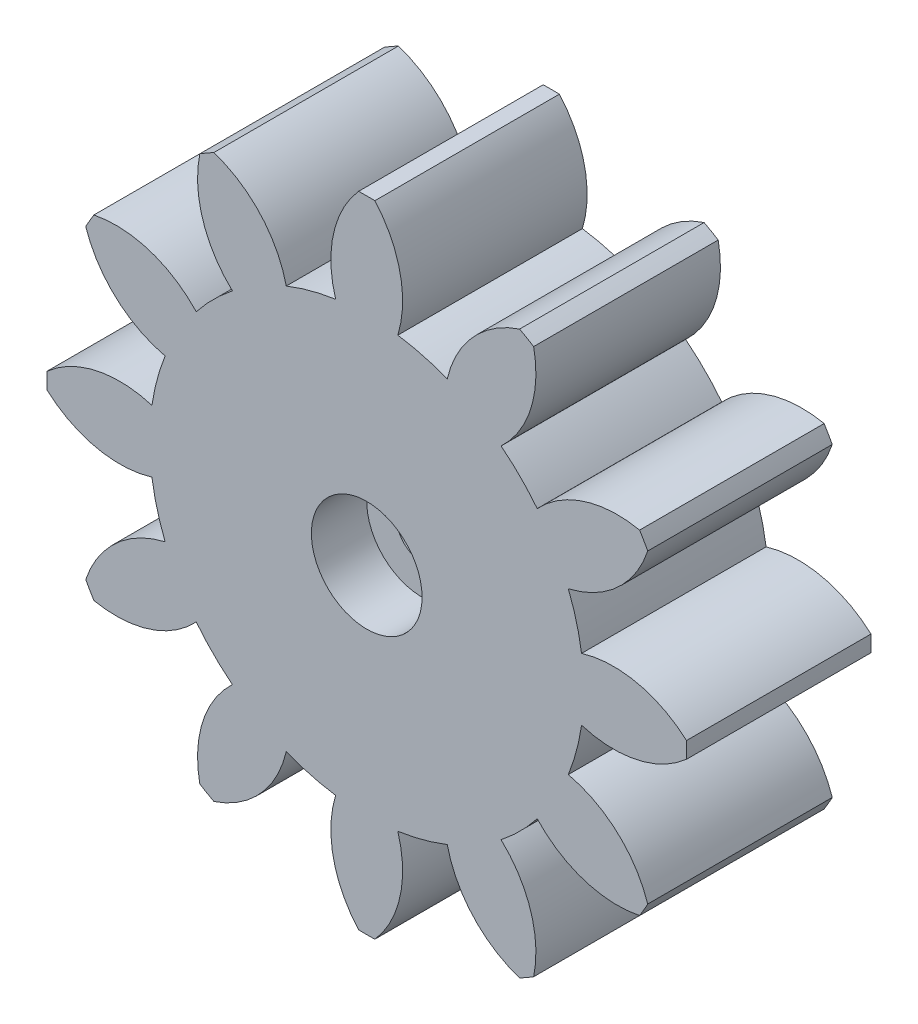
from build123d import *

# Parameters (mm, degrees)
BOSS_EXTRUDE1_DEPTH = 10
SKETCH3_R           = 3
CUT_EXTRUDE1_DEPTH  = 3
SKETCH4_R           = 3
CUT_EXTRUDE2_DEPTH  = 5
CUT_EXTRUDE3_REACH  = 7
SKETCH5_R           = 1.375
CUT_EXTRUDE4_DEPTH  = 0.4


with BuildPart() as part:
    # Sketch1 → Boss-Extrude1 (new body)
    with BuildSketch(Plane.XY):
        with BuildLine():
            ThreePointArc((10.92443124, -4.361437941), (11.362069294, -3.044457292), (11.641553947, -1.685099566))
            ThreePointArc((11.641553947, -1.685099566), (14.648632583, -1.806960077), (17.329910897, -0.440168758))
            ThreePointArc((17.329910897, -0.440168758), (17.3355, 0), (17.329910897, 0.440168758))
            ThreePointArc((17.329910897, 0.440168758), (14.648632583, 1.806960077), (11.641553947, 1.685099566))
            ThreePointArc((11.641553947, 1.685099566), (11.362069294, 3.044457292), (10.92443124, 4.361437941))
            ThreePointArc((10.92443124, 4.361437941), (13.589567986, 5.759442961), (15.228227462, 8.283758122))
            ThreePointArc((15.228227462, 8.283758122), (15.012983387, 8.66775), (14.788058703, 9.046152775))
            ThreePointArc((14.788058703, 9.046152775), (11.782607909, 8.889189622), (9.239331674, 7.280116005))
            ThreePointArc((9.239331674, 7.280116005), (8.317612002, 8.317612002), (7.280116005, 9.239331674))
            ThreePointArc((7.280116005, 9.239331674), (8.889189622, 11.782607909), (9.046152775, 14.788058703))
            ThreePointArc((9.046152775, 14.788058703), (8.66775, 15.012983387), (8.283758122, 15.228227462))
            ThreePointArc((8.283758122, 15.228227462), (5.759442961, 13.589567986), (4.361437941, 10.92443124))
            ThreePointArc((4.361437941, 10.92443124), (3.044457292, 11.362069294), (1.685099566, 11.641553947))
            ThreePointArc((1.685099566, 11.641553947), (1.806960077, 14.648632583), (0.440168758, 17.329910897))
            ThreePointArc((0.440168758, 17.329910897), (0, 17.3355), (-0.440168758, 17.329910897))
            ThreePointArc((-0.440168758, 17.329910897), (-1.806960077, 14.648632583), (-1.685099566, 11.641553947))
            ThreePointArc((-1.685099566, 11.641553947), (-3.044457292, 11.362069294), (-4.361437941, 10.92443124))
            ThreePointArc((-4.361437941, 10.92443124), (-5.759442961, 13.589567986), (-8.283758122, 15.228227462))
            ThreePointArc((-8.283758122, 15.228227462), (-8.66775, 15.012983387), (-9.046152775, 14.788058703))
            ThreePointArc((-9.046152775, 14.788058703), (-8.889189622, 11.782607909), (-7.280116005, 9.239331674))
            ThreePointArc((-7.280116005, 9.239331674), (-8.317612002, 8.317612002), (-9.239331674, 7.280116005))
            ThreePointArc((-9.239331674, 7.280116005), (-11.782607909, 8.889189622), (-14.788058703, 9.046152775))
            ThreePointArc((-14.788058703, 9.046152775), (-15.012983387, 8.66775), (-15.228227462, 8.283758122))
            ThreePointArc((-15.228227462, 8.283758122), (-13.589567986, 5.759442961), (-10.92443124, 4.361437941))
            ThreePointArc((-10.92443124, 4.361437941), (-11.362069294, 3.044457292), (-11.641553947, 1.685099566))
            ThreePointArc((-11.641553947, 1.685099566), (-14.648632583, 1.806960077), (-17.329910897, 0.440168758))
            ThreePointArc((-17.329910897, 0.440168758), (-17.3355, 0), (-17.329910897, -0.440168758))
            ThreePointArc((-17.329910897, -0.440168758), (-14.648632583, -1.806960077), (-11.641553947, -1.685099566))
            ThreePointArc((-11.641553947, -1.685099566), (-11.362069294, -3.044457292), (-10.92443124, -4.361437941))
            ThreePointArc((-10.92443124, -4.361437941), (-13.589567986, -5.759442961), (-15.228227462, -8.283758122))
            ThreePointArc((-15.228227462, -8.283758122), (-15.012983387, -8.66775), (-14.788058703, -9.046152775))
            ThreePointArc((-14.788058703, -9.046152775), (-11.782607909, -8.889189622), (-9.239331674, -7.280116005))
            ThreePointArc((-9.239331674, -7.280116005), (-8.317612002, -8.317612002), (-7.280116005, -9.239331674))
            ThreePointArc((-7.280116005, -9.239331674), (-8.889189622, -11.782607909), (-9.046152775, -14.788058703))
            ThreePointArc((-9.046152775, -14.788058703), (-8.66775, -15.012983387), (-8.283758122, -15.228227462))
            ThreePointArc((-8.283758122, -15.228227462), (-5.759442961, -13.589567986), (-4.361437941, -10.92443124))
            ThreePointArc((-4.361437941, -10.92443124), (-3.044457292, -11.362069294), (-1.685099566, -11.641553947))
            ThreePointArc((-1.685099566, -11.641553947), (-1.806960077, -14.648632583), (-0.440168758, -17.329910897))
            ThreePointArc((-0.440168758, -17.329910897), (0, -17.3355), (0.440168758, -17.329910897))
            ThreePointArc((0.440168758, -17.329910897), (1.806960077, -14.648632583), (1.685099566, -11.641553947))
            ThreePointArc((1.685099566, -11.641553947), (3.044457292, -11.362069294), (4.361437941, -10.92443124))
            ThreePointArc((4.361437941, -10.92443124), (5.759442961, -13.589567986), (8.283758122, -15.228227462))
            ThreePointArc((8.283758122, -15.228227462), (8.66775, -15.012983387), (9.046152775, -14.788058703))
            ThreePointArc((9.046152775, -14.788058703), (8.889189622, -11.782607909), (7.280116005, -9.239331674))
            ThreePointArc((7.280116005, -9.239331674), (8.317612002, -8.317612002), (9.239331674, -7.280116005))
            ThreePointArc((9.239331674, -7.280116005), (11.782607909, -8.889189622), (14.788058703, -9.046152775))
            ThreePointArc((14.788058703, -9.046152775), (15.012983387, -8.66775), (15.228227462, -8.283758122))
            ThreePointArc((15.228227462, -8.283758122), (13.589567986, -5.759442961), (10.92443124, -4.361437941))
        make_face()
    extrude(amount=BOSS_EXTRUDE1_DEPTH)

    # Sketch3 → Cut-Extrude1 (cut)
    with BuildSketch(Plane.XY.offset(10)):
        Circle(SKETCH3_R)
    extrude(amount=-CUT_EXTRUDE1_DEPTH, mode=Mode.SUBTRACT)

    # Sketch4 → Cut-Extrude2 (cut)
    with BuildSketch(Plane(origin=(0, 0, 0), x_dir=(-1, 0, 0), z_dir=(0, 0, -1))):
        Circle(SKETCH4_R)
    extrude(amount=-CUT_EXTRUDE2_DEPTH, mode=Mode.SUBTRACT)

    # Sketch5 → Cut-Extrude3 (cut, up to next)
    with BuildSketch(Plane(origin=(0, 0, 5), x_dir=(-1, 0, 0), z_dir=(0, 0, -1)), mode=Mode.PRIVATE) as cut_extrude3_sk1:
        Circle(SKETCH5_R)
    cut_extrude3_tool1 = extrude(cut_extrude3_sk1.sketch, amount=-CUT_EXTRUDE3_REACH, mode=Mode.PRIVATE) & part.part
    add(cut_extrude3_tool1.solids().sort_by_distance((0, 0, 5))[0], mode=Mode.SUBTRACT)

    # Sketch6 → Cut-Extrude4 (cut)
    with BuildSketch(Plane(origin=(0, 0, 0), x_dir=(-1, 0, 0), z_dir=(0, 0, -1))):
        Polygon((-2.618216479, 7.598722954), (-1.369925881, 7.598722954), (-1.397062633, 7.408765689), (-1.914356971, 7.408765689), (-2.18275641, 5.482056288), (-2.37398571, 5.482056288), (-2.105586271, 7.408765689), (-2.645353231, 7.408765689), align=None)
        with BuildLine():
            add(Edge.make_bspline(
                [(-0.466780849, 7.055987912), (-0.450230711, 7.05582637), (-0.417344464, 7.055505377), (-0.368540996, 7.050389965), (-0.320631892, 7.043455272), (-0.273890681, 7.033209653), (-0.228274333, 7.020039405), (-0.183797047, 7.003718771), (-0.139886963, 6.985373988), (-0.097861943, 6.963061744), (-0.056959643, 6.93914658), (-0.018469172, 6.912248414), (0.018217553, 6.883553528), (0.05209848, 6.852068656), (0.083565028, 6.818384713), (0.113001423, 6.782640371), (0.140098105, 6.744546559), (0.164595462, 6.704227452), (0.186767697, 6.662267959), (0.205810076, 6.618582201), (0.221812473, 6.573454595), (0.235635063, 6.527284032), (0.245748638, 6.479469202), (0.252716265, 6.430299353), (0.25780439, 6.379794636), (0.25811986, 6.345639936), (0.258279247, 6.328383745)],
                knots=[0, 0, 0, 0, 4.9626e-05, 9.861e-05, 0.000147062, 0.000194801, 0.000242036, 0.000289383, 0.000336874, 0.000384665, 0.000432005, 0.000478934, 0.000525421, 0.000571629, 0.000617526, 0.000663618, 0.000710444, 0.000757639, 0.000805055, 0.000852714, 0.00090046, 0.000948628, 0.000997195, 0.001046906, 0.001097579, 0.001149324, 0.001149324, 0.001149324, 0.001149324], degree=3))
            add(Edge.make_bspline(
                [(0.258279247, 6.328383745), (0.258039783, 6.308578593), (0.257564863, 6.269299702), (0.25111703, 6.210994824), (0.242013556, 6.153590639), (0.228820877, 6.097203636), (0.211893663, 6.041919503), (0.190810327, 5.98797899), (0.166897365, 5.934727262), (0.138391513, 5.883395436), (0.107072302, 5.833870752), (0.073382761, 5.786755537), (0.036549617, 5.742935538), (-0.002372315, 5.701702817), (-0.04403848, 5.66345401), (-0.088426282, 5.628104243), (-0.135229578, 5.595522836), (-0.184676123, 5.566327033), (-0.235762168, 5.539867628), (-0.289219479, 5.517520108), (-0.344037548, 5.497877287), (-0.400776526, 5.482306102), (-0.458924002, 5.469780542), (-0.519048579, 5.461676665), (-0.580721407, 5.455726724), (-0.622519609, 5.455190096), (-0.643593749, 5.454919536)],
                knots=[0, 0, 0, 0, 5.9386e-05, 0.000117778, 0.000175775, 0.00023368, 0.000291352, 0.00034907, 0.000407322, 0.000466339, 0.000525038, 0.000583054, 0.000639949, 0.000696635, 0.000753052, 0.000809471, 0.000866752, 0.000923981, 0.00098163, 0.001039198, 0.001097669, 0.001156204, 0.001215581, 0.001275965, 0.001338116, 0.001401316, 0.001401316, 0.001401316, 0.001401316], degree=3))
            add(Edge.make_bspline(
                [(-0.643593749, 5.454919536), (-0.669493428, 5.455383045), (-0.720215087, 5.456290778), (-0.79439634, 5.466548474), (-0.865066012, 5.482132761), (-0.932596844, 5.503609688), (-0.996247222, 5.532258194), (-1.056572504, 5.566773789), (-1.113195168, 5.607790827), (-1.165981922, 5.654584393), (-1.213474215, 5.70648827), (-1.255599117, 5.761915733), (-1.290839566, 5.821150442), (-1.31984552, 5.88380972), (-1.342346636, 5.949908511), (-1.358542659, 6.019333173), (-1.367836177, 6.092239873), (-1.369220429, 6.141933883), (-1.369925881, 6.167259279)],
                knots=[0, 0, 0, 0, 7.7651e-05, 0.000152071, 0.000224184, 0.000294581, 0.000364239, 0.000433188, 0.000502737, 0.00057362, 0.000644441, 0.00071347, 0.000782116, 0.000850791, 0.000920249, 0.000991216, 0.00106432, 0.001140294, 0.001140294, 0.001140294, 0.001140294], degree=3))
            add(Edge.make_bspline(
                [(-1.369925881, 6.167259279), (-1.369686634, 6.187346849), (-1.369212104, 6.227189251), (-1.362759891, 6.286341002), (-1.353696191, 6.344455032), (-1.340515163, 6.40142391), (-1.323365754, 6.45698532), (-1.303239948, 6.51160935), (-1.278207847, 6.564567741), (-1.250581409, 6.616609619), (-1.219162465, 6.666555184), (-1.184856791, 6.713974777), (-1.147928001, 6.75876754), (-1.107808488, 6.800408128), (-1.065080124, 6.839424555), (-1.019448587, 6.875464179), (-0.9715212, 6.909223719), (-0.920623878, 6.939512396), (-0.868016329, 6.966960034), (-0.813961342, 6.990907617), (-0.758740152, 7.010651127), (-0.702629226, 7.02747186), (-0.645186655, 7.040029408), (-0.586743519, 7.049425439), (-0.527104511, 7.055120684), (-0.487004359, 7.055697173), (-0.466780849, 7.055987912)],
                knots=[0, 0, 0, 0, 6.0234e-05, 0.000119469, 0.000178303, 0.000236621, 0.000294699, 0.000352663, 0.000411092, 0.000470279, 0.000529337, 0.000587944, 0.000645762, 0.000703341, 0.000761269, 0.000819212, 0.000877673, 0.00093701, 0.000996749, 0.001055602, 0.001114215, 0.001172576, 0.001231214, 0.001290467, 0.001350084, 0.001410741, 0.001410741, 0.001410741, 0.001410741], degree=3))
        make_face()
        with BuildLine():
            add(Edge.make_bspline(
                [(-0.472293002, 6.866030647), (-0.503747094, 6.865022695), (-0.566133209, 6.863023522), (-0.658065178, 6.845395471), (-0.74697014, 6.81671419), (-0.8179001, 6.783908088), (-0.872314578, 6.752977498), (-0.910614571, 6.727193913), (-0.946742967, 6.69944908), (-0.979981554, 6.669196258), (-1.011627398, 6.637641618), (-1.040171419, 6.603265542), (-1.066329268, 6.566962809), (-1.097983096, 6.516104928), (-1.130880322, 6.448766532), (-1.159486048, 6.363291926), (-1.176996833, 6.273551961), (-1.178969506, 6.212282932), (-1.179968616, 6.181251667)],
                knots=[0, 0, 0, 0, 9.4292e-05, 0.000187019, 0.000279676, 0.000373968, 0.00042088, 0.000467332, 0.000512367, 0.000557404, 0.000602079, 0.000646324, 0.000691278, 0.000736223, 0.000825918, 0.000915352, 0.001005996, 0.001099018, 0.001099018, 0.001099018, 0.001099018], degree=3))
            add(Edge.make_bspline(
                [(-1.179968616, 6.181251667), (-1.1794568, 6.161867569), (-1.178451954, 6.123810792), (-1.171245103, 6.068109016), (-1.158915609, 6.015297828), (-1.141843388, 5.965306456), (-1.120166741, 5.91788484), (-1.093381959, 5.873158688), (-1.061329114, 5.831519246), (-1.024961279, 5.793010338), (-0.984651842, 5.758346576), (-0.941503542, 5.727691836), (-0.895161957, 5.701906395), (-0.845807108, 5.681429065), (-0.794011633, 5.664525813), (-0.73908174, 5.653428903), (-0.681546468, 5.645797717), (-0.642065378, 5.645187438), (-0.62196915, 5.644876801)],
                knots=[0, 0, 0, 0, 5.8145e-05, 0.000114157, 0.000168153, 0.000220581, 0.000272377, 0.000324297, 0.000376622, 0.000429712, 0.000482923, 0.000535862, 0.000588248, 0.000641641, 0.000695949, 0.000751417, 0.000809532, 0.000869779, 0.000869779, 0.000869779, 0.000869779], degree=3))
            add(Edge.make_bspline(
                [(-0.62196915, 5.644876801), (-0.590524141, 5.645933886), (-0.528763332, 5.648010096), (-0.438477158, 5.664456418), (-0.352929935, 5.691901598), (-0.272103007, 5.729454032), (-0.197778454, 5.777916968), (-0.130845563, 5.836279067), (-0.071984641, 5.904158073), (-0.022332757, 5.980832092), (0.017761416, 6.063614509), (0.047409032, 6.150361963), (0.064739616, 6.24049149), (0.067121094, 6.301457184), (0.068321982, 6.332199851)],
                knots=[0, 0, 0, 0, 9.4292e-05, 0.000185198, 0.000274236, 0.000363199, 0.000451756, 0.000539509, 0.000628779, 0.000720394, 0.000812747, 0.00090406, 0.000994703, 0.001086905, 0.001086905, 0.001086905, 0.001086905], degree=3))
            add(Edge.make_bspline(
                [(0.068321982, 6.332199851), (0.067596039, 6.357703768), (0.066178212, 6.407515064), (0.052490613, 6.479882494), (0.031000633, 6.547823061), (0.000738925, 6.610911353), (-0.037430539, 6.668381502), (-0.083276432, 6.719204496), (-0.136040802, 6.763624821), (-0.195880428, 6.799826465), (-0.259971579, 6.829850478), (-0.328268896, 6.850426904), (-0.399271241, 6.863689881), (-0.447781945, 6.865244927), (-0.472293002, 6.866030647)],
                knots=[0, 0, 0, 0, 7.644e-05, 0.000149293, 0.000220094, 0.000289696, 0.000358492, 0.000426347, 0.000494371, 0.000564622, 0.000635577, 0.000706124, 0.000778068, 0.000851544, 0.000851544, 0.000851544, 0.000851544], degree=3))
        make_face(mode=Mode.SUBTRACT)
        with BuildLine():
            Line((0.776421608, 7.02885116), (0.967650909, 7.02885116))
            Line((0.967650909, 7.02885116), (0.932457933, 6.781228296))
            add(Edge.make_bspline(
                [(0.932457933, 6.781228296), (0.95525764, 6.803138201), (1.000002938, 6.846137227), (1.072430641, 6.902257527), (1.147347384, 6.949518214), (1.224612839, 6.988624493), (1.304555777, 7.018705794), (1.386761654, 7.040508587), (1.471519696, 7.05361281), (1.528855179, 7.05518975), (1.557875268, 7.055987912)],
                knots=[0, 0, 0, 0, 9.4812e-05, 0.000186072, 0.0002743, 0.0003602, 0.000445409, 0.000530053, 0.000614965, 0.000701991, 0.000701991, 0.000701991, 0.000701991], degree=3))
            add(Edge.make_bspline(
                [(1.557875268, 7.055987912), (1.584192867, 7.055471337), (1.635869811, 7.054456997), (1.711516019, 7.044905152), (1.783549539, 7.029392819), (1.851757058, 7.00707545), (1.916555994, 6.979203097), (1.97753369, 6.944637972), (2.03469906, 6.903571981), (2.087708757, 6.856739674), (2.136102849, 6.805245178), (2.178144461, 6.749427894), (2.214259749, 6.690243954), (2.242868415, 6.626972477), (2.266096403, 6.56066932), (2.282154079, 6.490571495), (2.29146759, 6.416830902), (2.292836344, 6.366430373), (2.293535658, 6.340680086)],
                knots=[0, 0, 0, 0, 7.8922e-05, 0.00015497, 0.000228326, 0.000299661, 0.000369924, 0.000439609, 0.000509503, 0.000580703, 0.000651501, 0.000721124, 0.000789988, 0.000859049, 0.000929045, 0.001000425, 0.00107437, 0.001151615, 0.001151615, 0.001151615, 0.001151615], degree=3))
            add(Edge.make_bspline(
                [(2.293535658, 6.340680086), (2.292756814, 6.310809362), (2.291221368, 6.2519209), (2.277974073, 6.16544013), (2.257296292, 6.082130479), (2.227913966, 6.001855526), (2.189452999, 5.925007168), (2.142976411, 5.851323822), (2.088249202, 5.780811596), (2.025651473, 5.714800282), (1.957599549, 5.654160368), (1.885694396, 5.600858306), (1.810960661, 5.555646543), (1.732910767, 5.518855238), (1.65201047, 5.489939258), (1.567893547, 5.469515219), (1.480912029, 5.457505724), (1.421945993, 5.455788903), (1.392086673, 5.454919536)],
                knots=[0, 0, 0, 0, 8.9567e-05, 0.000176576, 0.000261829, 0.000346742, 0.000432453, 0.000519152, 0.000607698, 0.000699783, 0.000791687, 0.000880816, 0.000967931, 0.001053283, 0.001139249, 0.001225223, 0.001312532, 0.001402099, 0.001402099, 0.001402099, 0.001402099], degree=3))
            add(Edge.make_bspline(
                [(1.392086673, 5.454919536), (1.36008557, 5.455877278), (1.297702186, 5.457744315), (1.207264878, 5.472815489), (1.122821871, 5.497537928), (1.043999269, 5.531754612), (0.971349306, 5.577623514), (0.904405343, 5.634036542), (0.843202, 5.701632583), (0.80859248, 5.752958596), (0.790838008, 5.779288526)],
                knots=[0, 0, 0, 0, 9.5962e-05, 0.000187069, 0.000274144, 0.000359388, 0.000443974, 0.000530946, 0.000621305, 0.000716485, 0.000716485, 0.000716485, 0.000716485], degree=3))
            Line((0.790838008, 5.779288526), (0.6678746, 4.912184493))
            Line((0.6678746, 4.912184493), (0.4766453, 4.912184493))
            Line((0.4766453, 4.912184493), (0.776421608, 7.02885116))
        make_face()
        with BuildLine():
            add(Edge.make_bspline(
                [(1.548547009, 6.866030647), (1.516964336, 6.86495289), (1.454651685, 6.862826475), (1.363186083, 6.846486382), (1.276118948, 6.818599665), (1.207326109, 6.786791703), (1.155258156, 6.75620511), (1.117925825, 6.730978147), (1.083157103, 6.70275848), (1.050269418, 6.672479986), (1.01928348, 6.639844547), (0.99047575, 6.604727345), (0.964099599, 6.567007331), (0.931552528, 6.514374386), (0.897108756, 6.44482235), (0.867718491, 6.356677676), (0.849813634, 6.264798947), (0.847534749, 6.202249068), (0.846383548, 6.170651373)],
                knots=[0, 0, 0, 0, 9.4715e-05, 0.000186873, 0.000277656, 0.000368335, 0.000413568, 0.000458728, 0.00050336, 0.000547771, 0.00059276, 0.000638256, 0.000683899, 0.000730733, 0.00082384, 0.000915956, 0.001008761, 0.001103502, 0.001103502, 0.001103502, 0.001103502], degree=3))
            add(Edge.make_bspline(
                [(0.846383548, 6.170651373), (0.846880401, 6.151687835), (0.84785555, 6.1144691), (0.855281967, 6.059969025), (0.866935692, 6.008041586), (0.883890562, 5.958899419), (0.90645881, 5.912918133), (0.93249753, 5.868896771), (0.964183934, 5.827973452), (1.000712796, 5.790469527), (1.040674711, 5.756302458), (1.083765653, 5.726286707), (1.129952142, 5.701296184), (1.178658217, 5.680303519), (1.230520431, 5.664740354), (1.284990487, 5.653397445), (1.342265236, 5.645810225), (1.3814616, 5.645191678), (1.401414931, 5.644876801)],
                knots=[0, 0, 0, 0, 5.6875e-05, 0.000111625, 0.000164699, 0.000216326, 0.000267151, 0.000318126, 0.00036952, 0.000421997, 0.000474932, 0.000527037, 0.000579218, 0.000632221, 0.000685872, 0.00074134, 0.000799033, 0.000858857, 0.000858857, 0.000858857, 0.000858857], degree=3))
            add(Edge.make_bspline(
                [(1.401414931, 5.644876801), (1.425190397, 5.645401392), (1.472082588, 5.64643604), (1.540974967, 5.655997841), (1.607293902, 5.671745595), (1.67090799, 5.693830093), (1.732023507, 5.721998881), (1.790365132, 5.756406863), (1.845607091, 5.797691261), (1.898274519, 5.843733104), (1.9462516, 5.894713202), (1.988627243, 5.949036817), (2.023867858, 6.006842659), (2.053425248, 6.067025352), (2.075840269, 6.130254393), (2.092225689, 6.196099235), (2.101446629, 6.26494454), (2.102861119, 6.311821231), (2.103578393, 6.335591945)],
                knots=[0, 0, 0, 0, 7.1296e-05, 0.000140616, 0.000208185, 0.0002755, 0.00034228, 0.000409763, 0.000478285, 0.000548887, 0.000619376, 0.000687989, 0.000755183, 0.000822125, 0.000888781, 0.000956038, 0.001025358, 0.001096673, 0.001096673, 0.001096673, 0.001096673], degree=3))
            add(Edge.make_bspline(
                [(2.103578393, 6.335591945), (2.103084075, 6.35497875), (2.102117155, 6.392900654), (2.094707841, 6.448394989), (2.082931157, 6.501085061), (2.066543011, 6.550976382), (2.044636177, 6.59774105), (2.017611356, 6.641345196), (1.986861031, 6.682940214), (1.950483335, 6.720388688), (1.910955275, 6.754734057), (1.867876985, 6.784605186), (1.821707243, 6.809606077), (1.772885678, 6.830695088), (1.720831223, 6.846087633), (1.666111937, 6.857566749), (1.608400351, 6.865104242), (1.568782329, 6.865717446), (1.548547009, 6.866030647)],
                knots=[0, 0, 0, 0, 5.8145e-05, 0.000113736, 0.000167637, 0.00021993, 0.000270956, 0.000322151, 0.000373626, 0.000425809, 0.000478422, 0.000530528, 0.000582709, 0.000635712, 0.000689768, 0.000745236, 0.00080335, 0.000864021, 0.000864021, 0.000864021, 0.000864021], degree=3))
        make_face(mode=Mode.SUBTRACT)
    extrude(amount=-CUT_EXTRUDE4_DEPTH, mode=Mode.SUBTRACT)


solid = part.part
